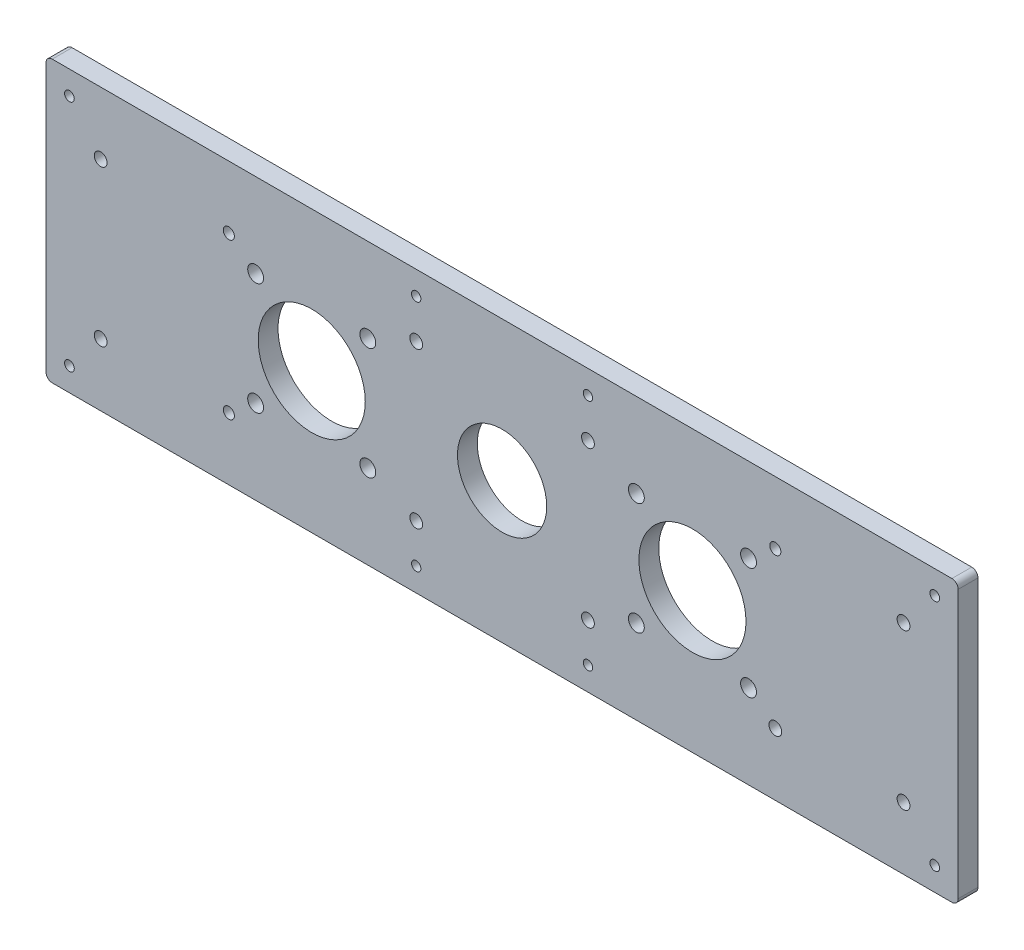
from build123d import *

# Parameters (mm, degrees)
SKETCH1_W           = 292.1
SKETCH1_H           = 89.8
SKETCH1_R           = 14.2875
SKETCH1_R_2         = 2.54
SKETCH1_R_3         = 17.145
BOSS_EXTRUDE1_DEPTH = 6.35
SKETCH2_R           = 2.05
CUT_EXTRUDE1_DEPTH  = 10
SKETCH3_R           = 1.55
SKETCH3_R_2         = 2.05
SKETCH3_R_3         = 1.5
CUT_EXTRUDE2_DEPTH  = 10
FILLET1_R           = 2
SKETCH4_R           = 2.05
SKETCH4_R_2         = 1.778
CUT_EXTRUDE4_DEPTH  = 7.35
SCALE1_SCALE        = 0.333333333


with BuildPart() as part:
    # Sketch1 → Boss-Extrude1 (new body)
    with BuildSketch(Plane.XY):
        with Locations((146.05, 44.9)):
            Rectangle(SKETCH1_W, SKETCH1_H)
        with Locations((146.05, 44.9)):
            Circle(SKETCH1_R, mode=Mode.SUBTRACT)
        with Locations((103.051585406, 62.859439014)):
            Circle(SKETCH1_R_2, mode=Mode.SUBTRACT)
        with Locations((103.049439014, 26.938414594)):
            Circle(SKETCH1_R_2, mode=Mode.SUBTRACT)
        with Locations((67.128414594, 26.940560986)):
            Circle(SKETCH1_R_2, mode=Mode.SUBTRACT)
        with Locations((67.130560986, 62.861585406)):
            Circle(SKETCH1_R_2, mode=Mode.SUBTRACT)
        with Locations((85.09, 44.9)):
            Circle(SKETCH1_R_3, mode=Mode.SUBTRACT)
        with Locations((189.050560986, 62.861585406)):
            Circle(SKETCH1_R_2, mode=Mode.SUBTRACT)
        with Locations((224.971585406, 62.859439014)):
            Circle(SKETCH1_R_2, mode=Mode.SUBTRACT)
        with Locations((224.969439014, 26.938414594)):
            Circle(SKETCH1_R_2, mode=Mode.SUBTRACT)
        with Locations((189.048414594, 26.940560986)):
            Circle(SKETCH1_R_2, mode=Mode.SUBTRACT)
        with Locations((207.01, 44.9)):
            Circle(SKETCH1_R_3, mode=Mode.SUBTRACT)
    extrude(amount=BOSS_EXTRUDE1_DEPTH)

    # Sketch2 → Cut-Extrude1 (cut)
    with BuildSketch(Plane.XY.offset(6.35)):
        with Locations((118.55, 20)):
            Circle(SKETCH2_R)
        with Locations((118.55, 69.8)):
            Circle(SKETCH2_R)
        with Locations((173.55, 20)):
            Circle(SKETCH2_R)
        with Locations((173.55, 69.8)):
            Circle(SKETCH2_R)
    extrude(amount=-CUT_EXTRUDE1_DEPTH, mode=Mode.SUBTRACT)

    # Sketch3 → Cut-Extrude2 (cut)
    with BuildSketch(Plane.XY.offset(6.35)):
        with Locations((284.6, 7.5)):
            Circle(SKETCH3_R)
        with Locations((7.5, 7.5)):
            Circle(SKETCH3_R)
        with Locations((7.5, 82.3)):
            Circle(SKETCH3_R)
        with Locations((284.6, 82.3)):
            Circle(SKETCH3_R)
        with Locations((274.6, 20)):
            Circle(SKETCH3_R_2)
        with Locations((17.5, 20)):
            Circle(SKETCH3_R_2)
        with Locations((17.5, 69.8)):
            Circle(SKETCH3_R_2)
        with Locations((274.6, 69.8)):
            Circle(SKETCH3_R_2)
        with Locations((173.55, 7.5)):
            Circle(SKETCH3_R_3)
        with Locations((173.55, 82.3)):
            Circle(SKETCH3_R_3)
        with Locations((118.55, 82.3)):
            Circle(SKETCH3_R_3)
        with Locations((118.55, 7.5)):
            Circle(SKETCH3_R_3)
    extrude(amount=-CUT_EXTRUDE2_DEPTH, mode=Mode.SUBTRACT)

    # Fillet1
    fillet1_edges = [part.edges().sort_by_distance(p)[0] for p in [
        (0, 89.8, 3.175),
        (292.1, 89.8, 3.175),
        (292.1, 0, 3.175),
        (0, 0, 3.175),
    ]]
    fillet(fillet1_edges, radius=FILLET1_R)

    # Sketch4 → Cut-Extrude4 (cut, through all)
    with BuildSketch(Plane.XY.offset(6.35)):
        with Locations((233.55, 20)):
            Circle(SKETCH4_R)
        with Locations((233.55, 69.8)):
            Circle(SKETCH4_R_2)
        with Locations((58.55, 69.8)):
            Circle(SKETCH4_R_2)
        with Locations((58.55, 20)):
            Circle(SKETCH4_R_2)
    extrude(amount=-CUT_EXTRUDE4_DEPTH, mode=Mode.SUBTRACT)


with BuildPart() as part_1:
    # Scale1: scaled about (146.037752534, 44.903485279, 3.175)
    add(part.part.scale(SCALE1_SCALE).moved(Location((97.358501689, 29.935656853, 2.116666667))))


solid = part_1.part
